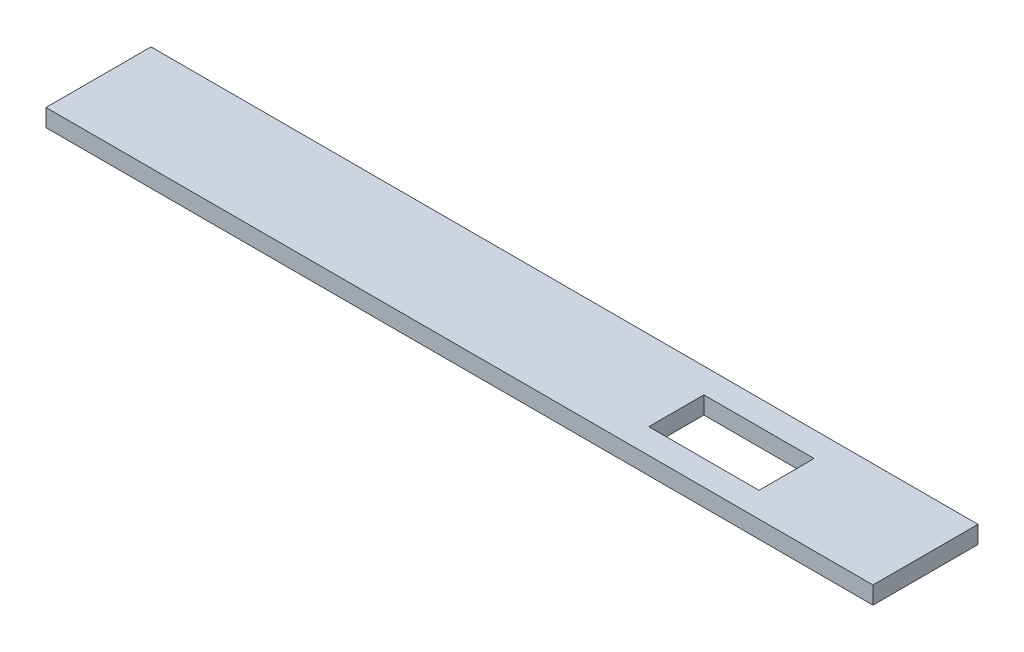
from build123d import *

# Parameters (mm, degrees)
SKETCH1_W           = 300.101088838
SKETCH1_H           = 6.35
BOSS_EXTRUDE1_DEPTH = 38.1
SKETCH2_W           = 40
SKETCH2_H           = 20
CUT_EXTRUDE1_DEPTH  = 7.35


with BuildPart() as part:
    # Sketch1 → Boss-Extrude1 (new body)
    with BuildSketch(Plane.XY.offset(-6.35)):
        with Locations((245.392650566, 49.505069687)):
            Rectangle(SKETCH1_W, SKETCH1_H)
    extrude(amount=BOSS_EXTRUDE1_DEPTH)

    # Sketch2 → Cut-Extrude1 (cut, through all)
    with BuildSketch(Plane(origin=(0, 52.680069687, 0), x_dir=(1, 0, 0), z_dir=(0, 1, 0))):
        with Locations((325.026890103, -12.7)):
            Rectangle(SKETCH2_W, SKETCH2_H)
    extrude(amount=-CUT_EXTRUDE1_DEPTH, mode=Mode.SUBTRACT)


solid = part.part
